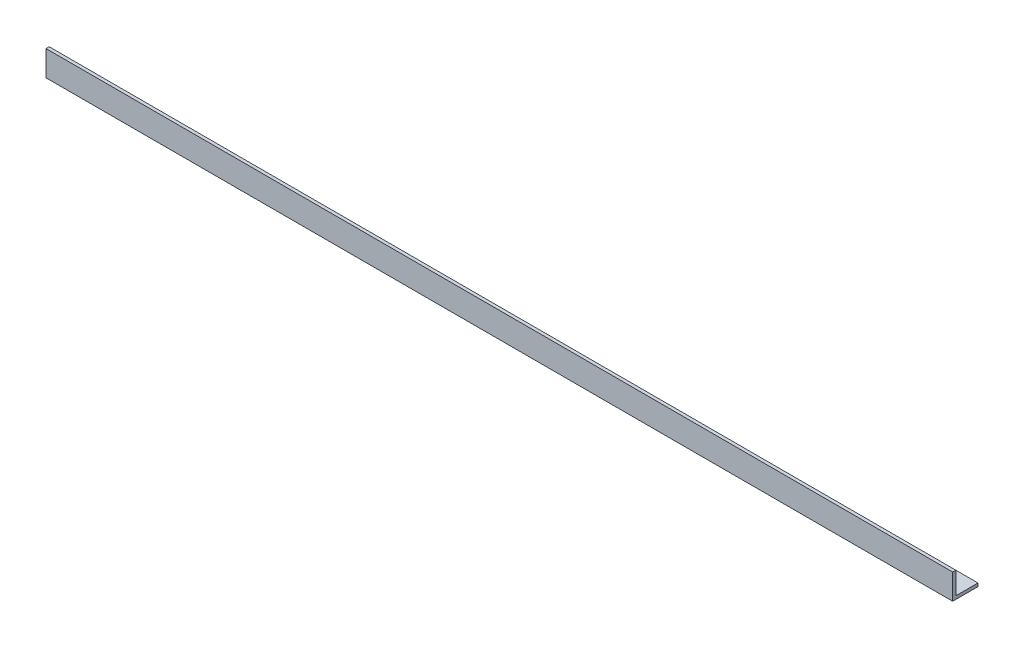
from build123d import *

# Parameters (mm, degrees)
BOSS_EXTRUDE1_DEPTH = 454.025


with BuildPart() as part:
    # Sketch1 → Boss-Extrude1 (new body, symmetric)
    with BuildSketch(Plane(origin=(0, 0, 0), x_dir=(0, 0, -1), z_dir=(1, 0, 0))):
        Polygon((0, 0), (0, 25.4), (3.175, 25.4), (3.175, 3.175), (25.4, 3.175), (25.4, 0), align=None)
    extrude(amount=BOSS_EXTRUDE1_DEPTH, both=True)


solid = part.part
